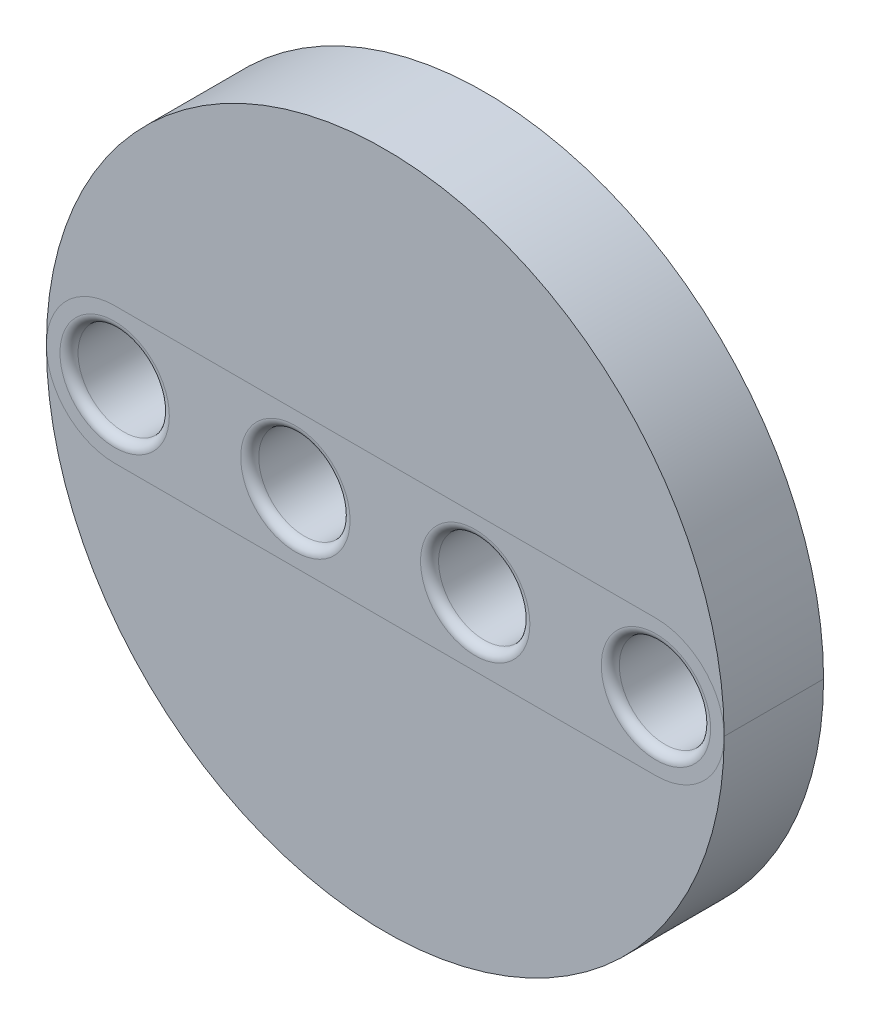
from build123d import *

# Parameters (mm, degrees)
SKETCH1_R             = 2.55
BOSS_EXTRUDE1_DEPTH   = 11
SKETCH2_R             = 5.05
CUT_EXTRUDE1_DEPTH    = 10
SKETCH3_R             = 2.55
BOSS_EXTRUDE2_DEPTH   = 1
BOSS_EXTRUDE3_DEPTH   = 11
BOSS_EXTRUDE3_2_DEPTH = 11
FILLET1_R             = 1


with BuildPart() as part:
    # Sketch1 → Boss-Extrude1 (new body)
    with BuildSketch(Plane.XY):
        with BuildLine():
            Line((0, 7.55), (59.9, 7.55))
            ThreePointArc((59.9, 7.55), (67.45, 0), (59.9, -7.55))
            Line((59.9, -7.55), (0, -7.55))
            ThreePointArc((0, -7.55), (-7.55, 0), (0, 7.55))
        make_face()
        with Locations((29.95, 0)):
            Circle(SKETCH1_R, mode=Mode.SUBTRACT)
        Circle(SKETCH1_R, mode=Mode.SUBTRACT)
        with Locations((59.9, 0)):
            Circle(SKETCH1_R, mode=Mode.SUBTRACT)
        with Locations((20, 0)):
            Circle(SKETCH1_R, mode=Mode.SUBTRACT)
        with Locations((39.9, 0)):
            Circle(SKETCH1_R, mode=Mode.SUBTRACT)
    extrude(amount=BOSS_EXTRUDE1_DEPTH)

    # Sketch2 → Cut-Extrude1 (cut)
    with BuildSketch(Plane.XY.offset(11)):
        Circle(SKETCH2_R)
        with Locations((59.9, 0)):
            Circle(SKETCH2_R)
        with Locations((20, 0)):
            Circle(SKETCH2_R)
        with Locations((39.9, 0)):
            Circle(SKETCH2_R)
    extrude(amount=-CUT_EXTRUDE1_DEPTH, mode=Mode.SUBTRACT)

    # Sketch3 → Boss-Extrude2 (add)
    with BuildSketch(Plane.XY.offset(11)):
        with Locations((29.95, 0)):
            Circle(SKETCH3_R)
    extrude(amount=-BOSS_EXTRUDE2_DEPTH)

    # Fillet1
    fillet1_edges = [part.edges().sort_by_distance(p)[0] for p in [
        (27.4, 0, 0),
        (-5.05, 0, 11),
        (34.85, 0, 11),
        (14.95, 0, 11),
        (54.85, 0, 11),
    ]]
    fillet(fillet1_edges, radius=FILLET1_R)


with BuildPart() as body_2:
    # Sketch4 → Boss-Extrude3 (new body)
    with BuildSketch(Plane.XY.offset(11)):
        with BuildLine():
            ThreePointArc((-7.55, 3.1e-08), (29.949999984, -37.5), (67.45, 0))
            ThreePointArc((67.45, 0), (65.238656198, -5.338656198), (59.9, -7.55))
            Line((59.9, -7.55), (0, -7.55))
            ThreePointArc((0, -7.55), (-5.338656209, -5.338656187), (-7.55, 3.1e-08))
        make_face()
    extrude(amount=-BOSS_EXTRUDE3_DEPTH)


with BuildPart() as body_3:
    # Sketch4 → Boss-Extrude3 2 (new body)
    with BuildSketch(Plane.XY.offset(11)):
        with BuildLine():
            ThreePointArc((59.9, 7.55), (65.238656198, 5.338656198), (67.45, 0))
            ThreePointArc((67.45, 0), (29.950000016, 37.5), (-7.55, 3.1e-08))
            ThreePointArc((-7.55, 3.1e-08), (-5.338656187, 5.338656209), (0, 7.55))
            Line((0, 7.55), (59.9, 7.55))
        make_face()
    extrude(amount=-BOSS_EXTRUDE3_2_DEPTH)


solid = Compound([part.part, body_2.part, body_3.part])
